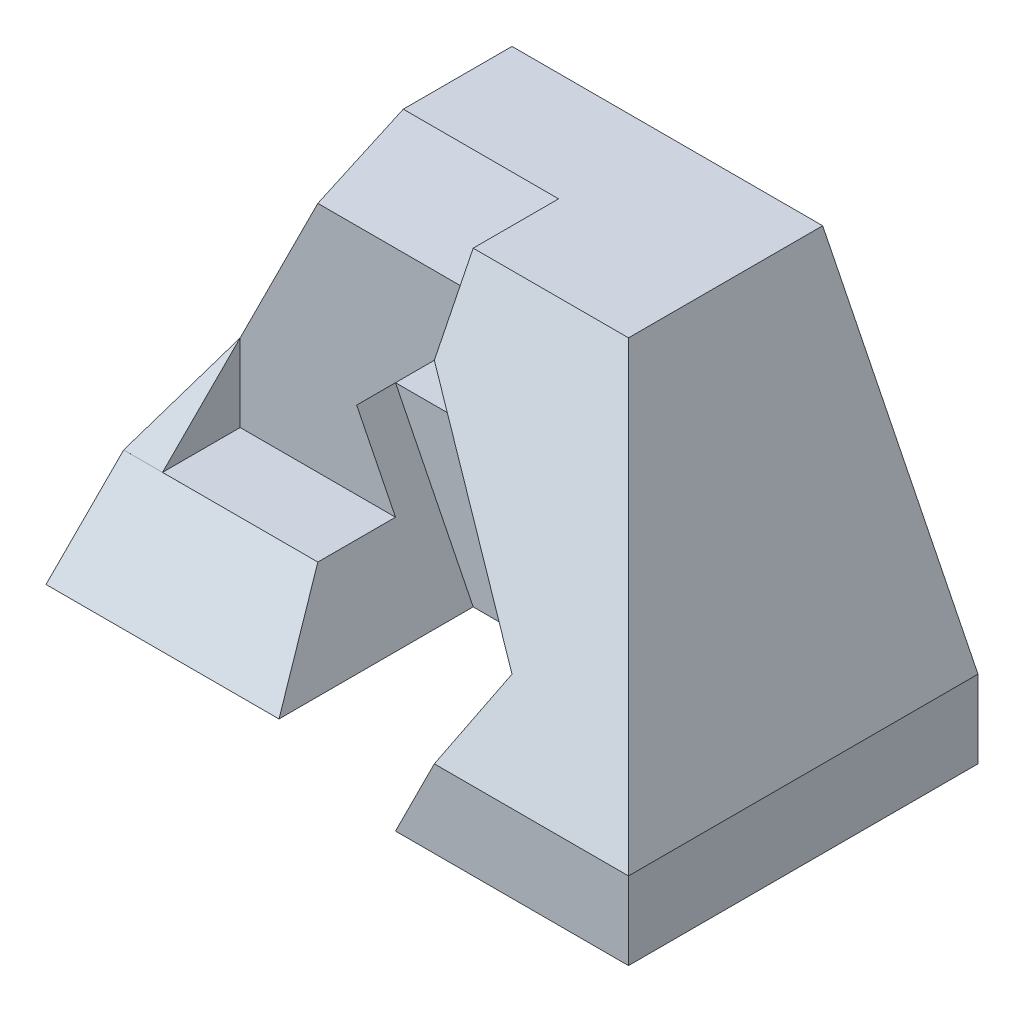
from build123d import *

# Parameters (mm, degrees)
BOSS_EXTRUDE1_DEPTH  = 90
CUT_EXTRUDE1_DEPTH   = 251
CUT_EXTRUDE7_DEPTH   = 40
CUT_EXTRUDE8_DEPTH   = 20
SKETCH9_W            = 70
SKETCH9_H            = 10
CUT_EXTRUDE9_DEPTH   = 190
SKETCH10_W           = 39.999
SKETCH10_H           = 29.999
CUT_EXTRUDE13_DEPTH  = 190
CUT_EXTRUDE14_DEPTH  = 190
CUT_EXTRUDE15_DEPTH  = 190
BOSS_EXTRUDE2_DEPTH  = 34
SKETCH14_W           = 39.999
SKETCH14_H           = 20
BOSS_EXTRUDE3_DEPTH  = 34
BOSS_EXTRUDE4_DEPTH  = 34
CUT_EXTRUDE21_DEPTH  = 77
SKETCH21_W           = 43.001
SKETCH21_H           = 20
CUT_EXTRUDE26_DEPTH  = 77
SKETCH22_W           = 28.284271247
SKETCH22_H           = 44.001
CUT_EXTRUDE27_DEPTH  = 77
BOSS_EXTRUDE5_DEPTH  = 77
BOSS_EXTRUDE7_DEPTH  = 50
BOSS_EXTRUDE8_DEPTH  = 50
BOSS_EXTRUDE12_DEPTH = 50
SKETCH32_W           = 44.001
SKETCH32_H           = 44.77461291
CUT_EXTRUDE29_DEPTH  = 2
CUT_EXTRUDE30_DEPTH  = 26
CUT_EXTRUDE33_DEPTH  = 26
CUT_EXTRUDE34_DEPTH  = 26
CUT_EXTRUDE38_DEPTH  = 5
SKETCH39_W           = 17.510737787
SKETCH39_H           = 5.1178381
BOSS_EXTRUDE13_DEPTH = 5
BOSS_EXTRUDE14_DEPTH = 5
SKETCH41_W           = 36.425905646
SKETCH41_H           = 30.361438292
BOSS_EXTRUDE17_DEPTH = 5
SKETCH43_W           = 4
SKETCH43_H           = 20
CUT_EXTRUDE39_DEPTH  = 64
SKETCH44_W           = 50
SKETCH44_H           = 4
CUT_EXTRUDE40_DEPTH  = 64
SKETCH45_W           = 120
SKETCH45_H           = 89.443166314
CUT_EXTRUDE43_DEPTH  = 64
SKETCH47_W           = 22.113315132
SKETCH47_H           = 22.285790595
BOSS_EXTRUDE19_DEPTH = 2
SKETCH48_W           = 120
SKETCH48_H           = 89.4427191
CUT_EXTRUDE44_DEPTH  = 5
CUT_EXTRUDE47_DEPTH  = 5
BOSS_EXTRUDE24_DEPTH = 30
BOSS_EXTRUDE26_DEPTH = 30
SKETCH56_W           = 32.299156512
SKETCH56_H           = 27.21956411
BOSS_EXTRUDE27_DEPTH = 30
SKETCH57_W           = 40.001
SKETCH57_H           = 25.586983612
BOSS_EXTRUDE28_DEPTH = 30
SKETCH61_W           = 48.915417123
SKETCH61_H           = 22.361126989
CUT_EXTRUDE55_DEPTH  = 20
BOSS_EXTRUDE30_DEPTH = 10
CUT_EXTRUDE56_DEPTH  = 79
CUT_EXTRUDE57_DEPTH  = 79
CUT_EXTRUDE58_DEPTH  = 79
CUT_EXTRUDE59_DEPTH  = 10
CUT_EXTRUDE64_DEPTH  = 20
BOSS_EXTRUDE32_DEPTH = 20
CUT_EXTRUDE65_DEPTH  = 49
SKETCH73_W           = 58.518906985
SKETCH73_H           = 24.994806596
CUT_EXTRUDE66_DEPTH  = 49
SKETCH75_W           = 20
SKETCH75_H           = 56.568542508
BOSS_EXTRUDE33_DEPTH = 2
CUT_EXTRUDE69_DEPTH  = 29
CUT_EXTRUDE70_DEPTH  = 29
CUT_EXTRUDE72_DEPTH  = 2
SKETCH81_W           = 8.58676876
SKETCH81_H           = 2.828391771
CUT_EXTRUDE73_DEPTH  = 2
SKETCH82_W           = 29.228045829
SKETCH82_H           = 21.594351677
CUT_EXTRUDE76_DEPTH  = 40
CUT_EXTRUDE77_DEPTH  = 20
CUT_EXTRUDE82_DEPTH  = 40
CUT_EXTRUDE84_DEPTH  = 39.999
CUT_EXTRUDE85_DEPTH  = 0.0001
BOSS_EXTRUDE34_DEPTH = 2
CUT_EXTRUDE86_DEPTH  = 2
CUT_EXTRUDE88_DEPTH  = 56
BOSS_EXTRUDE40_DEPTH = 20
CUT_EXTRUDE89_DEPTH  = 20
BOSS_EXTRUDE41_DEPTH = 50
BOSS_EXTRUDE42_DEPTH = 40
BOSS_EXTRUDE43_DEPTH = 20
SKETCH102_W          = 60.001499975
SKETCH102_H          = 20
CUT_EXTRUDE90_DEPTH  = 20
BOSS_EXTRUDE44_DEPTH = 60
CUT_EXTRUDE91_DEPTH  = 60
CUT_EXTRUDE92_DEPTH  = 60
CUT_EXTRUDE93_DEPTH  = 10
CUT_EXTRUDE96_DEPTH  = 20
CUT_EXTRUDE98_DEPTH  = 20
BOSS_EXTRUDE45_DEPTH = 20
CUT_EXTRUDE99_DEPTH  = 20
CUT_EXTRUDE100_DEPTH = 10
CUT_EXTRUDE101_DEPTH = 142
CUT_EXTRUDE106_DEPTH = 39.999
CUT_EXTRUDE107_DEPTH = 10


with BuildPart() as part:
    # Sketch1 → Boss-Extrude1 (new body)
    with BuildSketch(Plane.XY):
        Polygon((0, 0), (0, 20), (40, 100), (120, 100), (160, 20), (160, 0), align=None)
    extrude(amount=BOSS_EXTRUDE1_DEPTH)

    # Sketch2 → Cut-Extrude1 (cut)
    with BuildSketch(Plane(origin=(0, 0, 0), x_dir=(0, 0, -1), z_dir=(1, 0, 0))):
        Polygon((-90, 100), (-50, 100), (-90, 20), align=None)
    extrude(amount=CUT_EXTRUDE1_DEPTH, mode=Mode.SUBTRACT)

    # Sketch7 → Cut-Extrude7 (cut)
    with BuildSketch(Plane.XY.offset(90)):
        Polygon((60, 0), (100, 0), (120, 40), (80, 80), (40, 40), align=None)
    extrude(amount=-CUT_EXTRUDE7_DEPTH, mode=Mode.SUBTRACT)

    # Sketch8 → Cut-Extrude8 (cut)
    with BuildSketch(Plane.XY.offset(50)):
        Polygon((40, 40), (120, 40), (80, 80), align=None)
    extrude(amount=-CUT_EXTRUDE8_DEPTH, mode=Mode.SUBTRACT)

    # Sketch9 → Cut-Extrude9 (cut)
    with BuildSketch(Plane(origin=(0, 0, 0), x_dir=(1, 0, 0), z_dir=(0, 1, 0))):
        with Locations((75, -85)):
            Rectangle(SKETCH9_W, SKETCH9_H)
    extrude(amount=CUT_EXTRUDE9_DEPTH, mode=Mode.SUBTRACT)

    # Sketch10 → Cut-Extrude13 (cut)
    with BuildSketch(Plane(origin=(0, 0, 0), x_dir=(-1, 0, 0), z_dir=(0, -1, 0))):
        with Locations((-19.9995, -75.0005)):
            Rectangle(SKETCH10_W, SKETCH10_H)
    extrude(amount=-CUT_EXTRUDE13_DEPTH, mode=Mode.SUBTRACT)

    # Sketch11 → Cut-Extrude14 (cut)
    with BuildSketch(Plane(origin=(40, 0, 0), x_dir=(0, 0, -1), z_dir=(1, 0, 0))):
        Polygon((-80, 40), (-80, 0), (-90, 0), (-90, 20), align=None)
    extrude(amount=-CUT_EXTRUDE14_DEPTH, mode=Mode.SUBTRACT)

    # Sketch12 → Cut-Extrude15 (cut)
    with BuildSketch(Plane(origin=(0, 0, 0), x_dir=(-1, 0, 0), z_dir=(0, -1, 0))):
        Polygon((-100, -80), (-100, -70), (-110, -75), (-110, -80), align=None)
        Polygon((-39.999, -80), (-60, -80), (-60, -70), align=None)
    extrude(amount=-CUT_EXTRUDE15_DEPTH, mode=Mode.SUBTRACT)

    # Sketch13 → Boss-Extrude2 (add)
    with BuildSketch(Plane.XY.offset(90)):
        Polygon((110, 20), (110, 0), (100, 0), align=None)
    extrude(amount=-BOSS_EXTRUDE2_DEPTH)

    # Sketch14 → Boss-Extrude3 (add)
    with BuildSketch(Plane.XY.offset(60.001)):
        with Locations((19.9995, 10)):
            Rectangle(SKETCH14_W, SKETCH14_H)
    extrude(amount=BOSS_EXTRUDE3_DEPTH)

    # Sketch15 → Boss-Extrude4 (add)
    with BuildSketch(Plane.XY.offset(94.001)):
        Polygon((39.999, 0), (60, 0), (39.999, 20), align=None)
    extrude(amount=-BOSS_EXTRUDE4_DEPTH)

    # Sketch17 → Cut-Extrude21 (cut)
    with BuildSketch(Plane.XY.offset(50)):
        Polygon((60, 0), (40, 40), (40, 20), align=None)
    extrude(amount=CUT_EXTRUDE21_DEPTH, mode=Mode.SUBTRACT)

    # Sketch21 → Cut-Extrude26 (cut)
    with BuildSketch(Plane(origin=(40, 0, 0), x_dir=(0, 0, -1), z_dir=(1, 0, 0))):
        with Locations((-71.5005, 30)):
            Rectangle(SKETCH21_W, SKETCH21_H)
    extrude(amount=-CUT_EXTRUDE26_DEPTH, mode=Mode.SUBTRACT)

    # Sketch22 → Cut-Extrude27 (cut)
    with BuildSketch(Plane(origin=(30, 30, 0), x_dir=(0.707106781, -0.707106781, 0), z_dir=(0.707106781, 0.707106781, 0))):
        with Locations((28.284271248, -72.0005)):
            Rectangle(SKETCH22_W, SKETCH22_H)
    extrude(amount=-CUT_EXTRUDE27_DEPTH, mode=Mode.SUBTRACT)

    # Sketch23 → Boss-Extrude5 (add)
    with BuildSketch(Plane.XY.offset(94.001)):
        Polygon((39.999, 19.999), (39.999, 0), (49.999, 0), (39.999333333, 19.999333333), align=None)
        Polygon((39.999, 19.999), (20, 0), (39.999, 0), align=None)
    extrude(amount=-BOSS_EXTRUDE5_DEPTH)

    # Sketch26 → Boss-Extrude7 (add)
    with BuildSketch(Plane(origin=(0, 44.338879347, 80.614312123), x_dir=(-1, 0, 0), z_dir=(0, -0.481927159, -0.876211284))):
        Polygon((-40, 63.524770438), (-39.999, -27.777409169), (0, -27.777409169), align=None)
    extrude(amount=BOSS_EXTRUDE7_DEPTH)

    # Sketch28 → Boss-Extrude8 (add)
    with BuildSketch(Plane.XY.offset(94.001)):
        Polygon((0, 0), (60, 0), (50, 20), (0, 20), align=None)
    extrude(amount=-BOSS_EXTRUDE8_DEPTH)

    # Sketch31 → Boss-Extrude12 (add)
    with BuildSketch(Plane.XY.offset(94.001)):
        Polygon((50, 20), (40.001, 40), (39.999, 20), align=None)
    extrude(amount=-BOSS_EXTRUDE12_DEPTH)

    # Sketch32 → Cut-Extrude29 (cut)
    with BuildSketch(Plane(origin=(48, 24, 0), x_dir=(0, 0, -1), z_dir=(0.894427191, 0.447213595, 0))):
        with Locations((-72.0005, -4.445509275)):
            Rectangle(SKETCH32_W, SKETCH32_H)
    extrude(amount=CUT_EXTRUDE29_DEPTH, mode=Mode.SUBTRACT)

    # Sketch33 → Cut-Extrude30 (cut)
    with BuildSketch(Plane.XZ):
        Polygon((0, 57.638190064), (2.048178967, 47.937387746), (39.999051204, 47.937387746), (39.999, 57.638190064), align=None)
    extrude(amount=CUT_EXTRUDE30_DEPTH, mode=Mode.SUBTRACT)

    # Sketch35 → Cut-Extrude33 (cut)
    with BuildSketch(Plane(origin=(11.650101548, 0, 2.459744274), x_dir=(0.206580732, 0, -0.978429559), z_dir=(0.978429559, 0, 0.206580732))):
        Polygon((-48.782961552, -4.096357934), (-56.394908865, 0), (-46.480242824, 0), align=None)
    extrude(amount=-CUT_EXTRUDE33_DEPTH, mode=Mode.SUBTRACT)

    # Sketch36 → Cut-Extrude34 (cut)
    with BuildSketch(Plane(origin=(2.063610836, 42.293706667, 82.523802497), x_dir=(0.999752475, -0.01014732, -0.019799527), z_dir=(0.022248357, 0.455980099, 0.889711841))):
        Polygon((117.965588634, 66.188562504), (37.965588634, 66.188562504), (-2.064121759, -25.074555041), (157.975492098, -23.249726974), align=None)
    extrude(amount=CUT_EXTRUDE34_DEPTH, mode=Mode.SUBTRACT)

    # Sketch38 → Cut-Extrude38 (cut)
    with BuildSketch(Plane(origin=(0, -24.338879347, 13.386687877), x_dir=(-1, 0, 0), z_dir=(0, -0.876211284, 0.481927159))):
        Polygon((0, -42.003280055), (-1.572481647, -42.003280055), (0, -50.503232507), align=None)
    extrude(amount=-CUT_EXTRUDE38_DEPTH, mode=Mode.SUBTRACT)

    # Sketch39 → Boss-Extrude13 (add)
    with BuildSketch(Plane.ZY):
        with Locations((54.561477416, 2.55891905)):
            Rectangle(SKETCH39_W, SKETCH39_H)
    extrude(amount=-BOSS_EXTRUDE13_DEPTH)

    # Sketch40 → Boss-Extrude14 (add)
    with BuildSketch(Plane(origin=(-8, 4, 0), x_dir=(0, 0, 1), z_dir=(-0.894427191, 0.447213595, 0))):
        Polygon((60.001, 84.968347077), (50, 17.88854382), (94.001, 17.88854382), align=None)
    extrude(amount=-BOSS_EXTRUDE14_DEPTH)

    # Sketch41 → Boss-Extrude17 (add)
    with BuildSketch(Plane(origin=(-8, 4, 0), x_dir=(0, 0, 1), z_dir=(-0.894427191, 0.447213595, 0))):
        with Locations((48.733378767, 33.069262966)):
            Rectangle(SKETCH41_W, SKETCH41_H)
    extrude(amount=-BOSS_EXTRUDE17_DEPTH)

    # Sketch43 → Cut-Extrude39 (cut)
    with BuildSketch(Plane.ZY):
        with Locations((92.001, 10)):
            Rectangle(SKETCH43_W, SKETCH43_H)
    extrude(amount=-CUT_EXTRUDE39_DEPTH, mode=Mode.SUBTRACT)

    # Sketch44 → Cut-Extrude40 (cut)
    with BuildSketch(Plane.XZ.offset(-20)):
        with Locations((25, 92.001)):
            Rectangle(SKETCH44_W, SKETCH44_H)
    extrude(amount=-CUT_EXTRUDE40_DEPTH, mode=Mode.SUBTRACT)

    # Sketch45 → Cut-Extrude43 (cut)
    with BuildSketch(Plane(origin=(0, 40, 80), x_dir=(1, 0, 0), z_dir=(0, 0.447213595, 0.894427191))):
        with Locations((60, 22.360456168)):
            Rectangle(SKETCH45_W, SKETCH45_H)
    extrude(amount=CUT_EXTRUDE43_DEPTH, mode=Mode.SUBTRACT)

    # Sketch47 → Boss-Extrude19 (add)
    with BuildSketch(Plane(origin=(0, 40, 80), x_dir=(1, 0, 0), z_dir=(0, 0.447213595, 0.894427191))):
        with Locations((51.032841939, -11.089641938)):
            Rectangle(SKETCH47_W, SKETCH47_H)
    extrude(amount=BOSS_EXTRUDE19_DEPTH)

    # Sketch48 → Cut-Extrude44 (cut)
    with BuildSketch(Plane(origin=(0, 40, 80), x_dir=(1, 0, 0), z_dir=(0, 0.447213595, 0.894427191))):
        with Locations((60, 22.360679775)):
            Rectangle(SKETCH48_W, SKETCH48_H)
    extrude(amount=CUT_EXTRUDE44_DEPTH, mode=Mode.SUBTRACT)

    # Sketch49 → Cut-Extrude47 (cut)
    with BuildSketch(Plane(origin=(0, 40, 80), x_dir=(1, 0, 0), z_dir=(0, 0.447213595, 0.894427191))):
        Polygon((40.0009998, -0.002235621), (39.999024063, -22.091645582), (50.0002, -22.361126989), align=None)
    extrude(amount=-CUT_EXTRUDE47_DEPTH, mode=Mode.SUBTRACT)

    # Sketch52 → Boss-Extrude24 (add)
    with BuildSketch(Plane.XY.offset(50)):
        Polygon((40.119078133, 40.119078133), (39.976184373, 40.047631253), (39.99942419, 40), align=None)
    extrude(amount=BOSS_EXTRUDE24_DEPTH)

    # Sketch53 → Boss-Extrude26 (add)
    with BuildSketch(Plane(origin=(0, 40, 80), x_dir=(1, 0, 0), z_dir=(0, 0.447213595, 0.894427191))):
        Polygon((39.999265842, 0.000297206), (39.999024063, -22.091645582), (50.0002, -22.361126989), align=None)
    extrude(amount=-BOSS_EXTRUDE26_DEPTH)

    # Sketch56 → Boss-Extrude27 (add)
    with BuildSketch(Plane(origin=(-8, 4, 0), x_dir=(0, 0, 1), z_dir=(-0.894427191, 0.447213595, 0))):
        with Locations((56.525769836, 33.806547561)):
            Rectangle(SKETCH56_W, SKETCH56_H)
    extrude(amount=-BOSS_EXTRUDE27_DEPTH)

    # Sketch57 → Boss-Extrude28 (add)
    with BuildSketch(Plane(origin=(48, 24, 0), x_dir=(0, 0, -1), z_dir=(0.894427191, 0.447213595, 0))):
        with Locations((-70.0005, 5.095479818)):
            Rectangle(SKETCH57_W, SKETCH57_H)
    extrude(amount=-BOSS_EXTRUDE28_DEPTH)

    # Sketch61 → Cut-Extrude55 (cut)
    with BuildSketch(Plane(origin=(0, 40, 80), x_dir=(1, 0, 0), z_dir=(0, 0.447213595, 0.894427191))):
        with Locations((34.457708561, -11.180563495)):
            Rectangle(SKETCH61_W, SKETCH61_H)
    extrude(amount=CUT_EXTRUDE55_DEPTH, mode=Mode.SUBTRACT)

    # Sketch62 → Boss-Extrude30 (add)
    with BuildSketch(Plane.XY.offset(30)):
        Polygon((80, 80), (40, 40), (120, 40), align=None)
    extrude(amount=BOSS_EXTRUDE30_DEPTH)

    # Sketch63 → Cut-Extrude56 (cut)
    with BuildSketch(Plane.XY.offset(40)):
        Polygon((80, 100), (40, 100), (0, 20), (40, 40), (80, 80), align=None)
        Polygon((0, 20), (50, 20), (40, 40), align=None)
    extrude(amount=CUT_EXTRUDE56_DEPTH, mode=Mode.SUBTRACT)

    # Sketch64 → Cut-Extrude57 (cut)
    with BuildSketch(Plane(origin=(0, 0, 0), x_dir=(0, 0, -1), z_dir=(1, 0, 0))):
        Polygon((-60, 80), (-40, 80), (-28, 100), (-50, 100), align=None)
    extrude(amount=CUT_EXTRUDE57_DEPTH, mode=Mode.SUBTRACT)

    # Sketch65 → Cut-Extrude58 (cut)
    with BuildSketch(Plane.ZY.offset(-80)):
        Polygon((40, 100), (28, 100), (40, 80), align=None)
    extrude(amount=CUT_EXTRUDE58_DEPTH, mode=Mode.SUBTRACT)

    # Sketch66 → Cut-Extrude59 (cut)
    with BuildSketch(Plane.XY.offset(50)):
        Polygon((40, 40), (120, 40), (100, 0), (60, 0), align=None)
    extrude(amount=-CUT_EXTRUDE59_DEPTH, mode=Mode.SUBTRACT)

    # Sketch67 → Cut-Extrude64 (cut)
    with BuildSketch(Plane(origin=(0, 0, 0), x_dir=(0, 0, -1), z_dir=(1, 0, 0))):
        Polygon((-80.001, 0), (-90.001, 0), (-90.001, 20), (-80, 40.002), (-40, 40.002), align=None)
    extrude(amount=CUT_EXTRUDE64_DEPTH, mode=Mode.SUBTRACT)

    # Sketch71 → Boss-Extrude32 (add)
    with BuildSketch(Plane.ZY):
        Polygon((60.001499975, 20), (40, 40), (40, 20), align=None)
    extrude(amount=-BOSS_EXTRUDE32_DEPTH)

    # Sketch72 → Cut-Extrude65 (cut)
    with BuildSketch(Plane.ZY.offset(-20)):
        Polygon((60.001499975, 20), (80.001, 0), (90.001, 0), (90, 20), align=None)
    extrude(amount=-CUT_EXTRUDE65_DEPTH, mode=Mode.SUBTRACT)

    # Sketch73 → Cut-Extrude66 (cut)
    with BuildSketch(Plane(origin=(0, 0.00450005, 90.000999775), x_dir=(-1, 0, 0), z_dir=(0, -5e-05, -0.999999999))):
        with Locations((-49.259453493, 7.498096677)):
            Rectangle(SKETCH73_W, SKETCH73_H)
    extrude(amount=-CUT_EXTRUDE66_DEPTH, mode=Mode.SUBTRACT)

    # Sketch75 → Boss-Extrude33 (add)
    with BuildSketch(Plane(origin=(0, 40.000499988, 40.001499975), x_dir=(1, 0, 0), z_dir=(0, 0.707097943, 0.70711562))):
        with Locations((10, -28.284271254)):
            Rectangle(SKETCH75_W, SKETCH75_H)
    extrude(amount=-BOSS_EXTRUDE33_DEPTH)

    # Sketch77 → Cut-Extrude69 (cut)
    with BuildSketch(Plane.ZY):
        Polygon((77.172608229, 0), (80.001, 0), (78.586768761, -1.414195885), align=None)
    extrude(amount=-CUT_EXTRUDE69_DEPTH, mode=Mode.SUBTRACT)

    # Sketch78 → Cut-Extrude70 (cut)
    with BuildSketch(Plane(origin=(0, 0, 40), x_dir=(-1, 0, 0), z_dir=(0, 0, -1))):
        Polygon((0, 20), (-8.58676876, 37.173537521), (0, 37.173537521), align=None)
    extrude(amount=-CUT_EXTRUDE70_DEPTH, mode=Mode.SUBTRACT)

    # Sketch80 → Cut-Extrude72 (cut)
    with BuildSketch(Plane(origin=(0, 38.586304102, 38.587268736), x_dir=(-1, 0, 0), z_dir=(0, -0.707097943, -0.70711562))):
        Polygon((-9.293152051, 0), (0, 0), (0, -1.997928687), (-8.58676876, -1.997928687), align=None)
    extrude(amount=-CUT_EXTRUDE72_DEPTH, mode=Mode.SUBTRACT)

    # Sketch81 → Cut-Extrude73 (cut)
    with BuildSketch(Plane.XZ.offset(-37.173537521)):
        with Locations((4.29338438, 41.414195885)):
            Rectangle(SKETCH81_W, SKETCH81_H)
    extrude(amount=-CUT_EXTRUDE73_DEPTH, mode=Mode.SUBTRACT)

    # Sketch82 → Cut-Extrude76 (cut)
    with BuildSketch(Plane(origin=(-8, 4, 0), x_dir=(0, 0, 1), z_dir=(-0.894427191, 0.447213595, 0))):
        with Locations((38.699840788, 41.014077253)):
            Rectangle(SKETCH82_W, SKETCH82_H)
    extrude(amount=CUT_EXTRUDE76_DEPTH, mode=Mode.SUBTRACT)

    # Sketch83 → Cut-Extrude77 (cut)
    with BuildSketch(Plane.ZY):
        Polygon((60.001499975, 20), (60.001499975, 0), (80.001, 0), align=None)
    extrude(amount=-CUT_EXTRUDE77_DEPTH, mode=Mode.SUBTRACT)

    # Sketch86 → Cut-Extrude82 (cut)
    with BuildSketch(Plane.XY.offset(40)):
        Polygon((80, 80), (120, 40), (40, 40), align=None)
    extrude(amount=-CUT_EXTRUDE82_DEPTH, mode=Mode.SUBTRACT)

    # Sketch87 → Cut-Extrude84 (cut)
    with BuildSketch(Plane(origin=(0, 0, 0), x_dir=(0, 0, -1), z_dir=(1, 0, 0))):
        Polygon((0, 20), (-25, 20), (0, 100), align=None)
    extrude(amount=CUT_EXTRUDE84_DEPTH, mode=Mode.SUBTRACT)

    # Sketch89 → Cut-Extrude85 (cut)
    with BuildSketch(Plane.ZY.offset(-39.999)):
        Polygon((0, 20), (25, 20), (0, 99.998), align=None)
    extrude(amount=-CUT_EXTRUDE85_DEPTH, mode=Mode.SUBTRACT)

    # Sketch90 → Boss-Extrude34 (add)
    with BuildSketch(Plane.ZY.offset(-39.9991)):
        Polygon((25, 20), (0, 99.998), (0, 20), align=None)
    extrude(amount=BOSS_EXTRUDE34_DEPTH)

    # Sketch91 → Cut-Extrude86 (cut)
    with BuildSketch(Plane.ZY.offset(-37.9991)):
        Polygon((0, 99.998), (0, 20), (25, 20), align=None)
    extrude(amount=-CUT_EXTRUDE86_DEPTH, mode=Mode.SUBTRACT)

    # Sketch95 → Cut-Extrude88 (cut)
    with BuildSketch(Plane(origin=(0, 0, 0), x_dir=(-1, 0, 0), z_dir=(0, 0, -1))):
        Polygon((-80, 100), (-80, 80), (-40, 40), (-50, 20), (0, 20), (-39.9991, 100), align=None)
    extrude(amount=-CUT_EXTRUDE88_DEPTH, mode=Mode.SUBTRACT)

    # Sketch96 → Boss-Extrude40 (add)
    with BuildSketch(Plane.XY.offset(40)):
        Polygon((40, 40), (120, 40), (100, 0), (60, 0), align=None)
    extrude(amount=BOSS_EXTRUDE40_DEPTH)

    # Sketch97 → Cut-Extrude89 (cut)
    with BuildSketch(Plane(origin=(0, 0, 56), x_dir=(-1, 0, 0), z_dir=(0, 0, -1))):
        Polygon((-20, 24.00160001), (-2.000800005, 24.00160001), (0, 20), (-20, 20), align=None)
    extrude(amount=-CUT_EXTRUDE89_DEPTH, mode=Mode.SUBTRACT)

    # Sketch98 → Boss-Extrude41 (add)
    with BuildSketch(Plane(origin=(0, 0, 0), x_dir=(-1, 0, 0), z_dir=(0, 0, -1))):
        Polygon((-80, 80), (-120, 40), (-40, 40), align=None)
    extrude(amount=-BOSS_EXTRUDE41_DEPTH)

    # Sketch99 → Boss-Extrude42 (add)
    with BuildSketch(Plane(origin=(0, 0, 0), x_dir=(-1, 0, 0), z_dir=(0, 0, -1))):
        Polygon((0, 20), (-40, 100), (-80, 100), (-80, 80), (-40, 40), (-50, 20), align=None)
    extrude(amount=-BOSS_EXTRUDE42_DEPTH)

    # Sketch100 → Boss-Extrude43 (add)
    with BuildSketch(Plane.ZY.offset(-20)):
        Polygon((60.001499975, 20), (60.001499975, 0), (80.001, 0), align=None)
    extrude(amount=BOSS_EXTRUDE43_DEPTH)

    # Sketch102 → Cut-Extrude90 (cut)
    with BuildSketch(Plane.ZY):
        with Locations((30.000749988, 10)):
            Rectangle(SKETCH102_W, SKETCH102_H)
    extrude(amount=-CUT_EXTRUDE90_DEPTH, mode=Mode.SUBTRACT)

    # Sketch103 → Boss-Extrude44 (add)
    with BuildSketch(Plane(origin=(0, 0, 0), x_dir=(-1, 0, 0), z_dir=(0, 0, -1))):
        Polygon((0, 20), (-20, 0), (-20, 20), align=None)
    extrude(amount=-BOSS_EXTRUDE44_DEPTH)

    # Sketch105 → Cut-Extrude91 (cut)
    with BuildSketch(Plane(origin=(80, 0, 0), x_dir=(0, 0, -1), z_dir=(1, 0, 0))):
        Polygon((-60, 80), (-40, 80), (-28, 100), (-50, 100), align=None)
    extrude(amount=-CUT_EXTRUDE91_DEPTH, mode=Mode.SUBTRACT)

    # Sketch106 → Cut-Extrude92 (cut)
    with BuildSketch(Plane.ZY.offset(-80)):
        Polygon((60, 80), (40, 80), (40, 40), (80, 40), align=None)
    extrude(amount=CUT_EXTRUDE92_DEPTH, mode=Mode.SUBTRACT)

    # Sketch107 → Cut-Extrude93 (cut)
    with BuildSketch(Plane.XY.offset(50)):
        Polygon((120, 40), (80, 40), (80, 80), align=None)
    extrude(amount=-CUT_EXTRUDE93_DEPTH, mode=Mode.SUBTRACT)

    # Sketch109 → Cut-Extrude96 (cut)
    with BuildSketch(Plane.XY.offset(60)):
        Polygon((50, 20), (50, 40), (40, 40), align=None)
    extrude(amount=-CUT_EXTRUDE96_DEPTH, mode=Mode.SUBTRACT)

    # Sketch111 → Cut-Extrude98 (cut)
    with BuildSketch(Plane.XY.offset(60)):
        Polygon((120, 40), (50, 40), (50, 20), (60, 0), (100, 0), align=None)
    extrude(amount=-CUT_EXTRUDE98_DEPTH, mode=Mode.SUBTRACT)

    # Sketch112 → Boss-Extrude45 (add)
    with BuildSketch(Plane(origin=(0, 0, 0), x_dir=(0, 0, -1), z_dir=(1, 0, 0))):
        Polygon((-60, 20), (-40, 39.999500025), (-40, 20), align=None)
    extrude(amount=BOSS_EXTRUDE45_DEPTH)

    # Sketch113 → Cut-Extrude99 (cut)
    with BuildSketch(Plane(origin=(0, 0, 40), x_dir=(-1, 0, 0), z_dir=(0, 0, -1))):
        Polygon((-9.999750012, 39.999500025), (0, 39.999500025), (0, 20), align=None)
    extrude(amount=-CUT_EXTRUDE99_DEPTH, mode=Mode.SUBTRACT)

    # Sketch114 → Cut-Extrude100 (cut)
    with BuildSketch(Plane(origin=(20, 0, 0), x_dir=(0, 0, -1), z_dir=(1, 0, 0))):
        Polygon((-40, 39.999500025), (-60.001499975, 20), (-40, 20), align=None)
    extrude(amount=-CUT_EXTRUDE100_DEPTH, mode=Mode.SUBTRACT)

    # Sketch115 → Cut-Extrude101 (cut)
    with BuildSketch(Plane.XY.offset(40)):
        Polygon((80, 80), (120, 40), (40, 40), align=None)
    extrude(amount=-CUT_EXTRUDE101_DEPTH, mode=Mode.SUBTRACT)

    # Sketch117 → Cut-Extrude106 (cut)
    with BuildSketch(Plane(origin=(0, 0, 0), x_dir=(0, 0, -1), z_dir=(1, 0, 0))):
        Polygon((0, 20), (-25, 20), (0, 100), align=None)
    extrude(amount=CUT_EXTRUDE106_DEPTH, mode=Mode.SUBTRACT)

    # Sketch118 → Cut-Extrude107 (cut)
    with BuildSketch(Plane.XY.offset(40)):
        Polygon((40, 40), (120, 40), (100, 0), (60, 0), align=None)
    extrude(amount=-CUT_EXTRUDE107_DEPTH, mode=Mode.SUBTRACT)


solid = part.part
